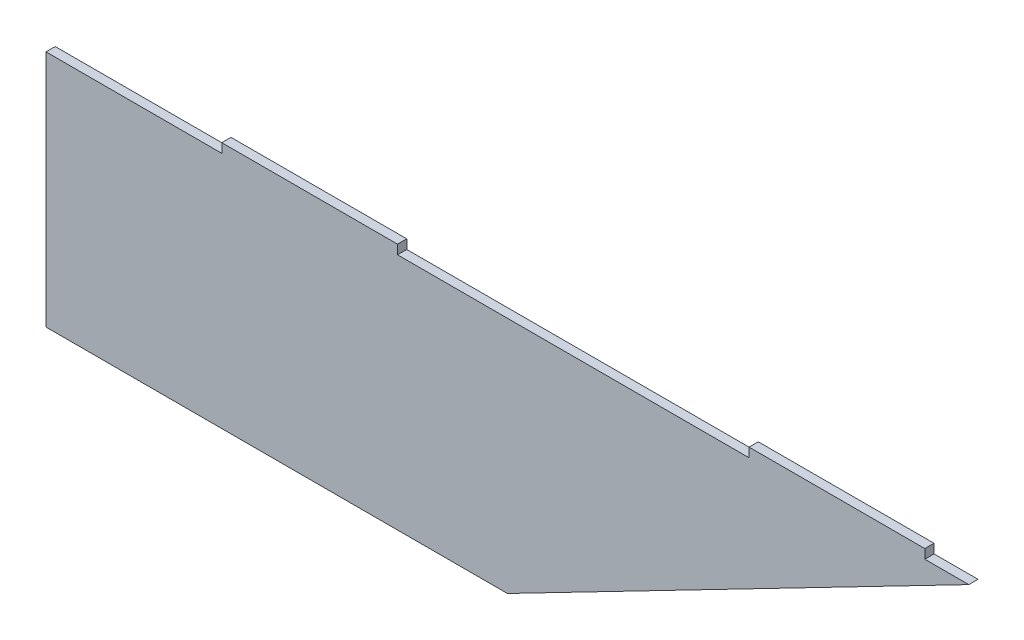
from build123d import *

# Parameters (mm, degrees)
RESSALTO_EXTRUS_O1_DEPTH = 3


with BuildPart() as part:
    # Esboço1 → Ressalto-extrusão1 (new body)
    with BuildSketch(Plane.XY):
        Polygon((0, 0), (0, 77.5), (57.142857143, 77.5), (57.142857143, 80.5), (114.285714286, 80.5), (114.285714286, 77.5), (228.571428571, 77.5), (228.571428571, 80.5), (285.714285714, 80.5), (285.714285714, 77.5), (300, 77.5), (150, 0), align=None)
    extrude(amount=RESSALTO_EXTRUS_O1_DEPTH)


solid = part.part
